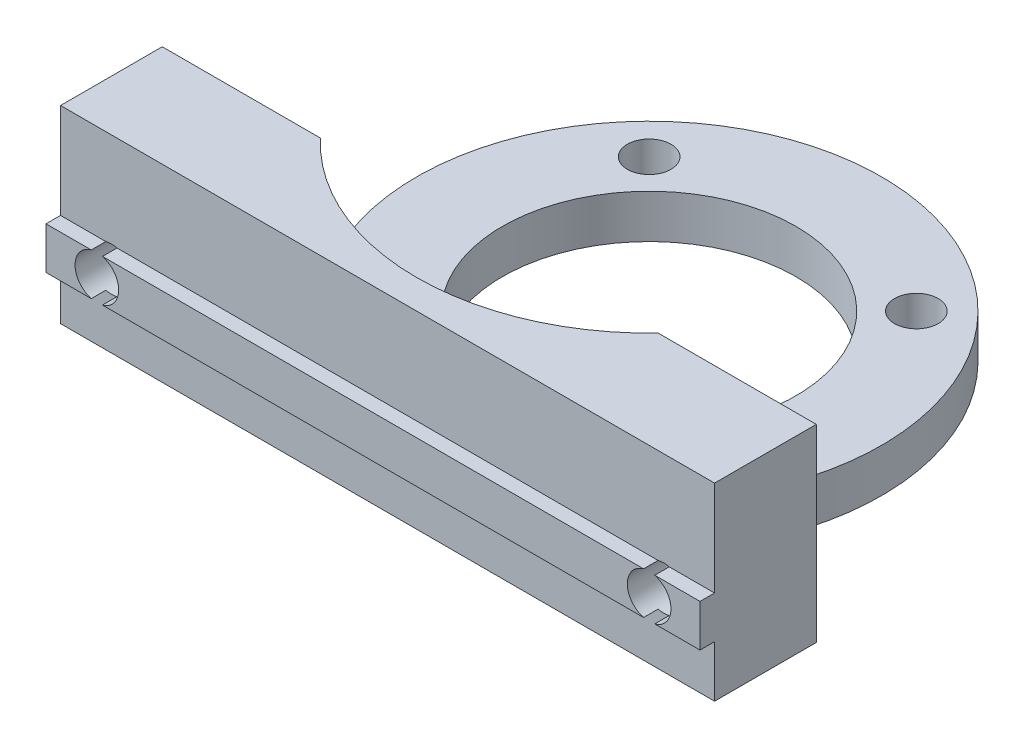
from build123d import *

# Parameters (mm, degrees)
SKETCH1_W           = 45
SKETCH1_H           = 13
MAIN_DEPTH          = 7
SKETCH4_W           = 45
SKETCH4_H           = 2.9
MAKERBEAMFIX_DEPTH  = 1
SKETCH5_R           = 1.5
MAKERBEAMHOLE_DEPTH = 9
SKETCH6_R           = 16
SKETCH6_R_2         = 10.1
MOTORFIX_DEPTH      = 3
SKETCH7_R           = 16
MOTORHOLE_DEPTH     = 10
SKETCH8_R           = 1.5
MOTORFIXHOLE_DEPTH  = 14
FILLET1_R           = 3


with BuildPart() as part:
    # Sketch1 → Main (new body)
    with BuildSketch(Plane.XY):
        Rectangle(SKETCH1_W, SKETCH1_H)
    extrude(amount=MAIN_DEPTH)

    # Sketch4 → MakerBeamFix (add)
    with BuildSketch(Plane.XY.offset(7)):
        with Locations((0, -1.5)):
            Rectangle(SKETCH4_W, SKETCH4_H)
    extrude(amount=MAKERBEAMFIX_DEPTH)

    # Sketch5 → MakerBeamHole (cut, through all)
    with BuildSketch(Plane.XY.offset(8)):
        with Locations((-19, -1.5)):
            Circle(SKETCH5_R)
        with Locations((19, -1.5)):
            Circle(SKETCH5_R)
    extrude(amount=-MAKERBEAMHOLE_DEPTH, mode=Mode.SUBTRACT)

    # Sketch6 → MotorFix (add)
    with BuildSketch(Plane(origin=(0, -6.5, 0), x_dir=(1, 0, 0), z_dir=(0, 1, 0))):
        with Locations((0, 11)):
            Circle(SKETCH6_R)
        with Locations((0, 11)):
            Circle(SKETCH6_R_2, mode=Mode.SUBTRACT)
    extrude(amount=MOTORFIX_DEPTH)

    # Sketch7 → MotorHole (cut)
    with BuildSketch(Plane(origin=(0, 6.5, 0), x_dir=(-1, 0, 0), z_dir=(0, -1, 0))):
        with Locations((0, 11)):
            Circle(SKETCH7_R)
    extrude(amount=MOTORHOLE_DEPTH, mode=Mode.SUBTRACT)

    # Sketch8 → MotorFixHole (cut, through all)
    with BuildSketch(Plane(origin=(0, 6.5, 0), x_dir=(1, 0, 0), z_dir=(0, 1, 0))):
        with Locations((9.192388155, 20.192388155)):
            Circle(SKETCH8_R)
        with Locations((-9.192388155, 20.192388155)):
            Circle(SKETCH8_R)
        with Locations((-9.192388155, 1.807611845)):
            Circle(SKETCH8_R)
        with Locations((9.192388155, 1.807611845)):
            Circle(SKETCH8_R)
    extrude(amount=-MOTORFIXHOLE_DEPTH, mode=Mode.SUBTRACT)

    # Fillet1
    fillet1_edges = [part.edges().sort_by_distance(p)[0] for p in [
        (-11.618950039, -5, 0),
        (11.618950039, -5, 0),
    ]]
    fillet(fillet1_edges, radius=FILLET1_R)


solid = part.part
